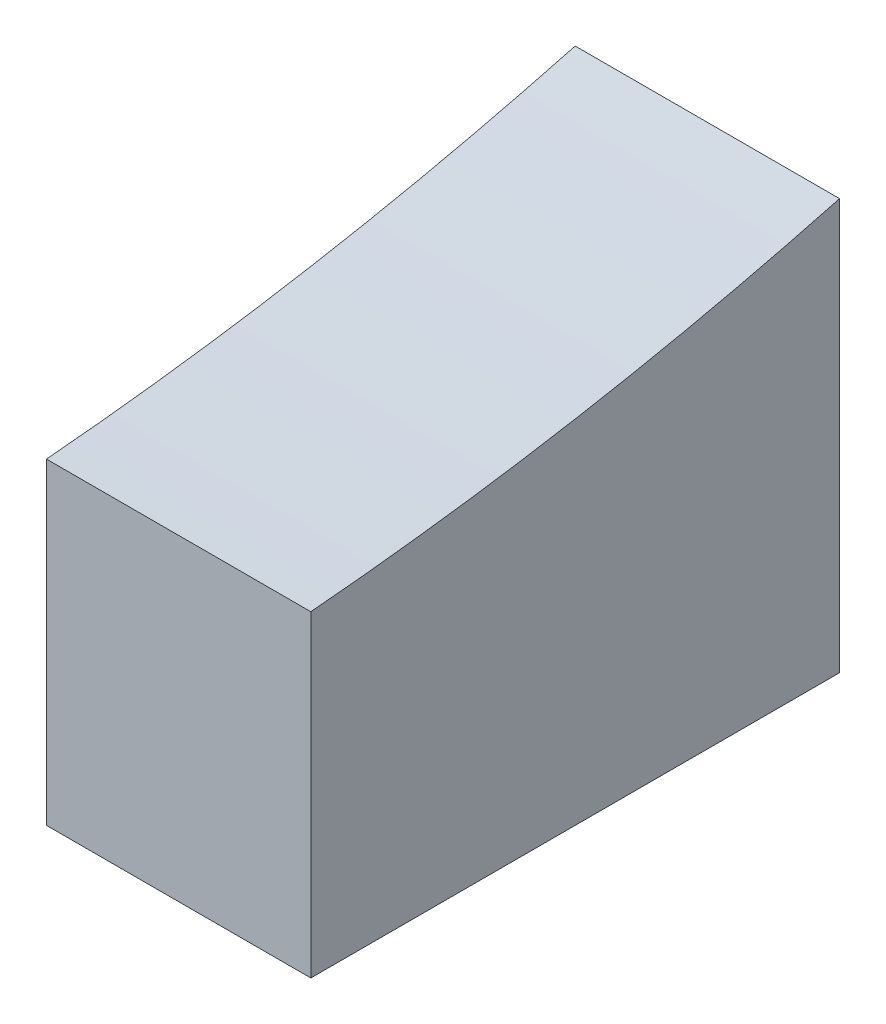
from build123d import *

# Parameters (mm, degrees)
EXTRUDE_1_DEPTH     = 10
EXTRUDE_2_DEPTH     = 10
SKETCH_2_R          = 3
CUT_EXTRUDE_1_DEPTH = 10


with BuildPart() as part:
    # 草图1 → 凸台-拉伸1 (new body)
    with BuildSketch(Plane(origin=(0, 0, 0), x_dir=(0, 0, -1), z_dir=(1, 0, 0))):
        with BuildLine():
            Line((10, 12), (10, 0))
            Line((10, 0), (30, 0))
            Line((30, 0), (30, 15.532515952))
            ThreePointArc((30, 15.532515952), (20.077840204, 13.3255511), (10, 12))
        make_face()
    extrude(amount=EXTRUDE_1_DEPTH)

    # 草图1<2> → 凸台-拉伸2 (add)
    with BuildSketch(Plane(origin=(0, 0, 0), x_dir=(0, 0, -1), z_dir=(1, 0, 0))):
        with BuildLine():
            Line((10, 12), (10, 0))
            Line((10, 0), (30, 0))
            Line((30, 0), (30, 15.532515952))
            ThreePointArc((30, 15.532515952), (20.077840204, 13.3255511), (10, 12))
        make_face()
    extrude(amount=EXTRUDE_2_DEPTH)

    # 草图2 → 切除-拉伸1 (cut)
    with BuildSketch(Plane.XZ):
        with Locations((5, -18)):
            Circle(SKETCH_2_R)
    extrude(amount=-CUT_EXTRUDE_1_DEPTH, mode=Mode.SUBTRACT)


solid = part.part
